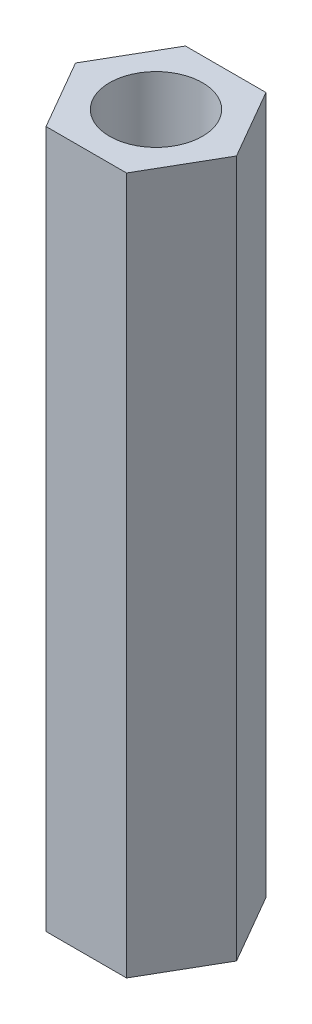
from build123d import *

# Parameters (mm, degrees)
SKETCH_1_R      = 2
EXTRUDE_1_DEPTH = 30


with BuildPart() as part:
    # 草图1 → 凸台-拉伸1 (new body)
    with BuildSketch(Plane(origin=(0, 0, 0), x_dir=(1, 0, 0), z_dir=(0, 1, 0))):
        Polygon((1.732050808, 3), (-1.732050808, 3), (-3.464101615, 0), (-1.732050808, -3), (1.732050808, -3), (3.464101615, 0), align=None)
        Circle(SKETCH_1_R, mode=Mode.SUBTRACT)
    extrude(amount=EXTRUDE_1_DEPTH)


solid = part.part
